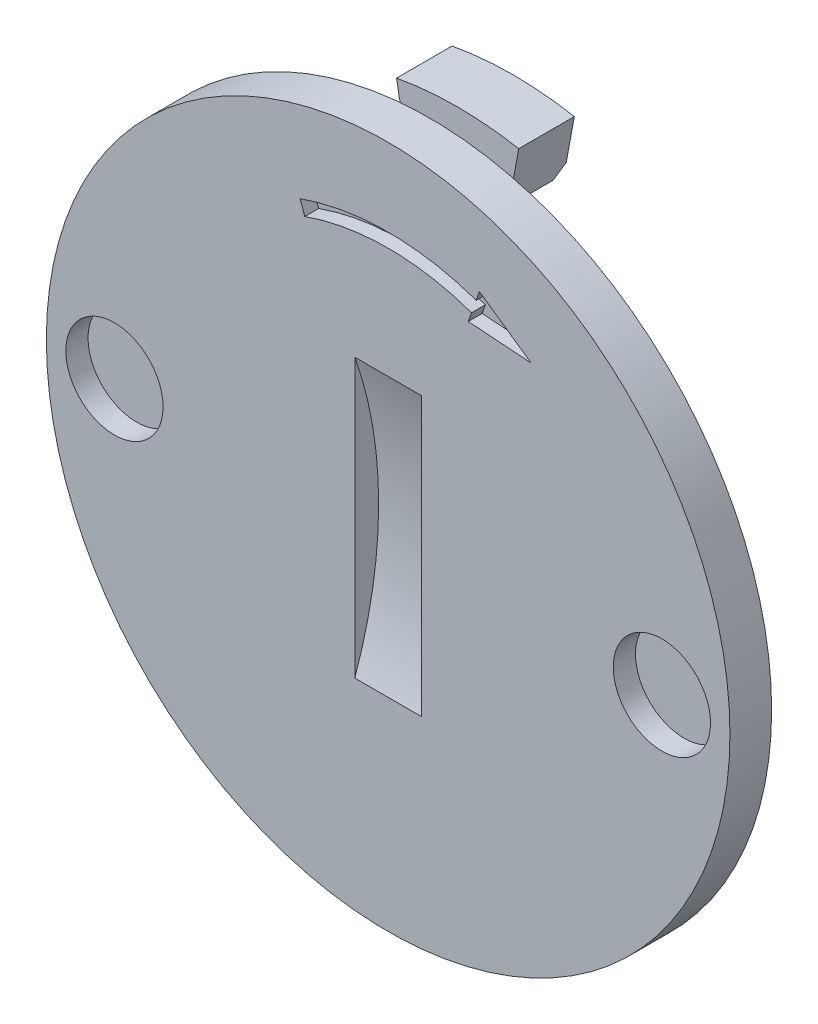
from build123d import *

# Parameters (mm, degrees)
SKICA1_R                      = 12.3
P_IDAT_VYSUNUT_M1_DEPTH       = 1.5
ODEBRAT_START                 = 1.5
SKICA1_6_R                    = 1.75
ODEBRAT_VYSUNUT_M3_DEPTH      = 0.8
P_IDAT_VYSUNUT_M3_DEPTH       = 3
P_IDAT_START                  = 1
P_IDAT_VYSUNUT_M4_DEPTH       = 2
ZKOSEN_1_SIZE                 = 0.4
KRUHOV_POLE1_COUNT            = 2
ZKOSEN_1_OF_KRUHOV_POLE1_SIZE = 0.4
ODEBRAT_VYSUNUT_M2_DEPTH      = 0.5
ODEBRAT_VYSUNUT_M1_DEPTH      = 1.2
ODEBRAT_VYSUNUT_M1_DEPTH_BACK = 1.2


with BuildPart() as part:
    # Skica1 → P_idat vysunut_m1 (new body)
    with BuildSketch(Plane.XY):
        Circle(SKICA1_R)
    extrude(amount=P_IDAT_VYSUNUT_M1_DEPTH)

    # Skica1_6 → Odebrat vysunut_m3 (cut)
    with BuildSketch(Plane.XY.offset(ODEBRAT_START)):
        with Locations((-9.85, 0)):
            Circle(SKICA1_6_R)
        with Locations((9.85, 0)):
            Circle(SKICA1_6_R)
    extrude(amount=-ODEBRAT_VYSUNUT_M3_DEPTH, mode=Mode.SUBTRACT)

    # Skica1_5 → P_idat vysunut_m3 (add)
    with BuildSketch(Plane.XY):
        with BuildLine():
            Line((-2, 10.867497412), (-1.837104072, 9.982361876))
            ThreePointArc((-1.837104072, 9.982361876), (0, 10.15), (1.837104072, 9.982361876))
            Line((1.837104072, 9.982361876), (2, 10.867497412))
            ThreePointArc((2, 10.867497412), (0, 11.05), (-2, 10.867497412))
        make_face()
    p_idat_vysunut_m3 = extrude(amount=-P_IDAT_VYSUNUT_M3_DEPTH)

    # Skica2 → P_idat vysunut_m4 (add)
    with BuildSketch(Plane(origin=(0, 0, 0), x_dir=(-1, 0, 0), z_dir=(0, 0, -1)).offset(P_IDAT_START)):
        with BuildLine():
            Line((-2, 10.867497412), (-2.199095023, 11.949329734))
            ThreePointArc((-2.199095023, 11.949329734), (0, 12.15), (2.199095023, 11.949329734))
            Line((2.199095023, 11.949329734), (2, 10.867497412))
            ThreePointArc((2, 10.867497412), (0, 11.05), (-2, 10.867497412))
        make_face()
    p_idat_vysunut_m4 = extrude(amount=P_IDAT_VYSUNUT_M4_DEPTH)

    # Zkosen_1
    zkosen_1_edges = [part.edges().sort_by_distance(p)[0] for p in [
        (0, 10.15, -3),
    ]]
    chamfer(zkosen_1_edges, length=ZKOSEN_1_SIZE)

    # Kruhov_ pole1: P_idat vysunut_m3, P_idat vysunut_m4 ×2 about axis
    kruhov_pole1_axis = Axis((0, 0, 0), (0, 0, 1))
    for i in range(1, KRUHOV_POLE1_COUNT):
        add(p_idat_vysunut_m3.rotate(kruhov_pole1_axis, i * 360 / KRUHOV_POLE1_COUNT))
        add(p_idat_vysunut_m4.rotate(kruhov_pole1_axis, i * 360 / KRUHOV_POLE1_COUNT))

    # Zkosen_1 of Kruhov_ pole1
    zkosen_1_of_kruhov_pole1_edges = [part.edges().sort_by_distance(p)[0] for p in [
        (0, -10.15, -3),
    ]]
    chamfer(zkosen_1_of_kruhov_pole1_edges, length=ZKOSEN_1_OF_KRUHOV_POLE1_SIZE)

    # Skica3 → Odebrat vysunut_m2 (cut)
    with BuildSketch(Plane.XY.offset(1.5)):
        with BuildLine():
            Line((-3.166666667, 8.956685895), (-3, 8.485281374))
            ThreePointArc((-3, 8.485281374), (0, 9), (3, 8.485281374))
            Line((3, 8.485281374), (2.883333333, 8.15529821))
            Line((2.883333333, 8.15529821), (5.144077535, 7.992400535))
            Line((5.144077535, 7.992400535), (3.283333333, 9.28666906))
            Line((3.283333333, 9.28666906), (3.166666667, 8.956685895))
            ThreePointArc((3.166666667, 8.956685895), (0, 9.5), (-3.166666667, 8.956685895))
        make_face()
    extrude(amount=-ODEBRAT_VYSUNUT_M2_DEPTH, mode=Mode.SUBTRACT)

    # Skica4 → Odebrat vysunut_m1 (cut, two sides)
    with BuildSketch(Plane(origin=(0, 0, 0), x_dir=(0, 0, -1), z_dir=(1, 0, 0))) as odebrat_vysunut_m1_sk:
        with BuildLine():
            Line((-1.5, 5), (-1.5, -5))
            ThreePointArc((-1.5, -5), (-0.642135624, 0), (-1.5, 5))
        make_face()
    extrude(amount=ODEBRAT_VYSUNUT_M1_DEPTH, mode=Mode.SUBTRACT)
    extrude(odebrat_vysunut_m1_sk.sketch, amount=-ODEBRAT_VYSUNUT_M1_DEPTH_BACK, mode=Mode.SUBTRACT)


solid = part.part
